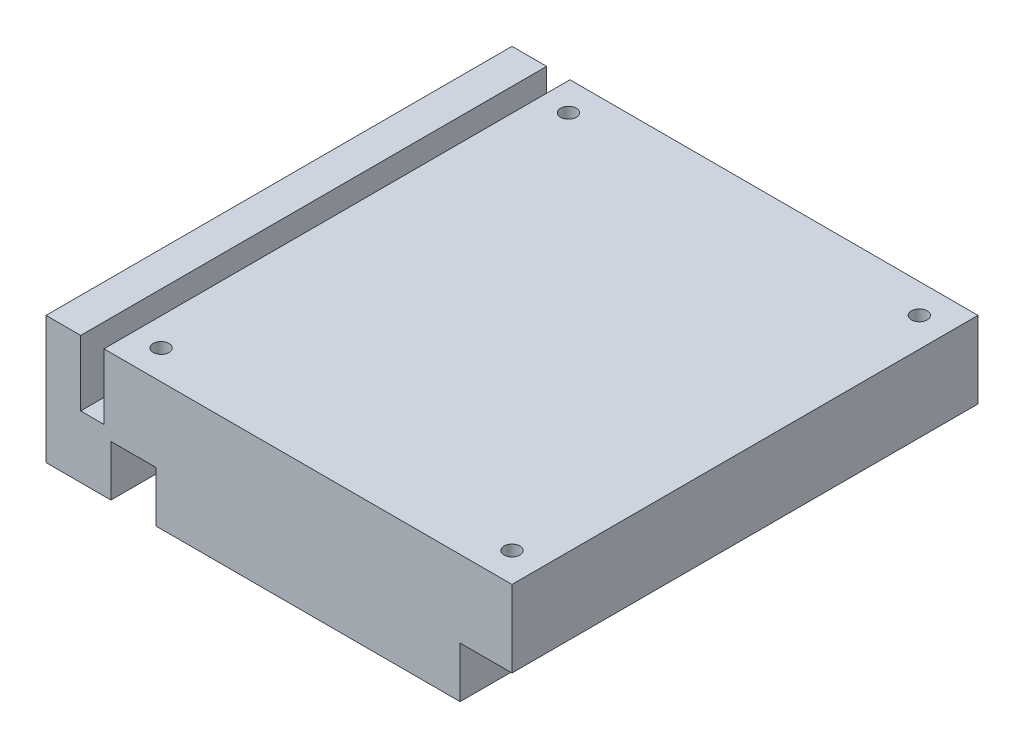
from build123d import *

# Parameters (mm, degrees)
SKETCH1_W           = 104.902
SKETCH1_H           = 104.902
BOSS_EXTRUDE1_DEPTH = 2.54
SKETCH2_W           = 91.861923629
SKETCH2_H           = 104.902
SKETCH2_W_2         = 7.806745179
BOSS_EXTRUDE2_DEPTH = 14.732
SKETCH3_R           = 1.778
CUT_EXTRUDE1_DEPTH  = 18.272
SKETCH4_W           = 68.459098584
SKETCH4_H           = 14.819221787
SKETCH4_H_2         = 13.598803865
SKETCH4_W_2         = 14.616932407
BOSS_EXTRUDE3_DEPTH = 11.43


with BuildPart() as part:
    # Sketch1 → Boss-Extrude1 (new body)
    with BuildSketch(Plane(origin=(0, 0, 0), x_dir=(1, 0, 0), z_dir=(0, 1, 0))):
        with Locations((52.451, 52.451)):
            Rectangle(SKETCH1_W, SKETCH1_H)
    extrude(amount=BOSS_EXTRUDE1_DEPTH)

    # Sketch2 → Boss-Extrude2 (add)
    with BuildSketch(Plane(origin=(0, 2.54, 0), x_dir=(1, 0, 0), z_dir=(0, 1, 0))):
        with Locations((58.971038185, 52.451)):
            Rectangle(SKETCH2_W, SKETCH2_H)
        with Locations((3.90337259, 52.451)):
            Rectangle(SKETCH2_W_2, SKETCH2_H)
    extrude(amount=BOSS_EXTRUDE2_DEPTH)

    # Sketch3 → Cut-Extrude1 (cut, through all)
    with BuildSketch(Plane(origin=(0, 17.272, 0), x_dir=(1, 0, 0), z_dir=(0, 1, 0))):
        with Locations((98.298, 6.604)):
            Circle(SKETCH3_R)
        with Locations((98.298, 98.298)):
            Circle(SKETCH3_R)
        with Locations((19.304, 6.604)):
            Circle(SKETCH3_R)
        with Locations((19.304, 98.298)):
            Circle(SKETCH3_R)
    extrude(amount=-CUT_EXTRUDE1_DEPTH, mode=Mode.SUBTRACT)

    # Sketch4 → Boss-Extrude3 (add)
    with BuildSketch(Plane.XZ):
        with Locations((58.99120595, -97.492389107)):
            Rectangle(SKETCH4_W, SKETCH4_H)
        with Locations((58.99120595, -6.799401933)):
            Rectangle(SKETCH4_W, SKETCH4_H_2)
        with Locations((7.308466204, -6.799401933)):
            Rectangle(SKETCH4_W_2, SKETCH4_H_2)
    extrude(amount=BOSS_EXTRUDE3_DEPTH)


solid = part.part
